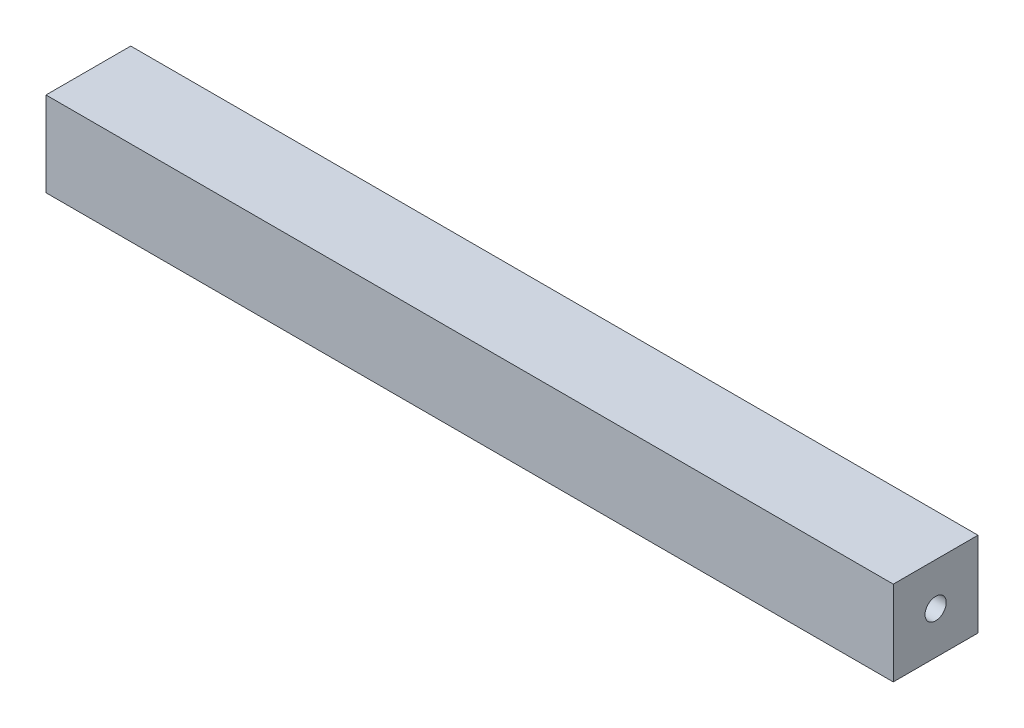
from build123d import *

# Parameters (mm, degrees)
SKETCH1_W           = 25.4
SKETCH1_H           = 25.4
SKETCH1_R           = 3.175
BOSS_EXTRUDE1_DEPTH = 127


with BuildPart() as part:
    # Sketch1 → Boss-Extrude1 (new body, symmetric)
    with BuildSketch(Plane(origin=(0, 0, 0), x_dir=(0, 0, -1), z_dir=(1, 0, 0))):
        Rectangle(SKETCH1_W, SKETCH1_H)
        Circle(SKETCH1_R, mode=Mode.SUBTRACT)
    extrude(amount=BOSS_EXTRUDE1_DEPTH, both=True)


solid = part.part
